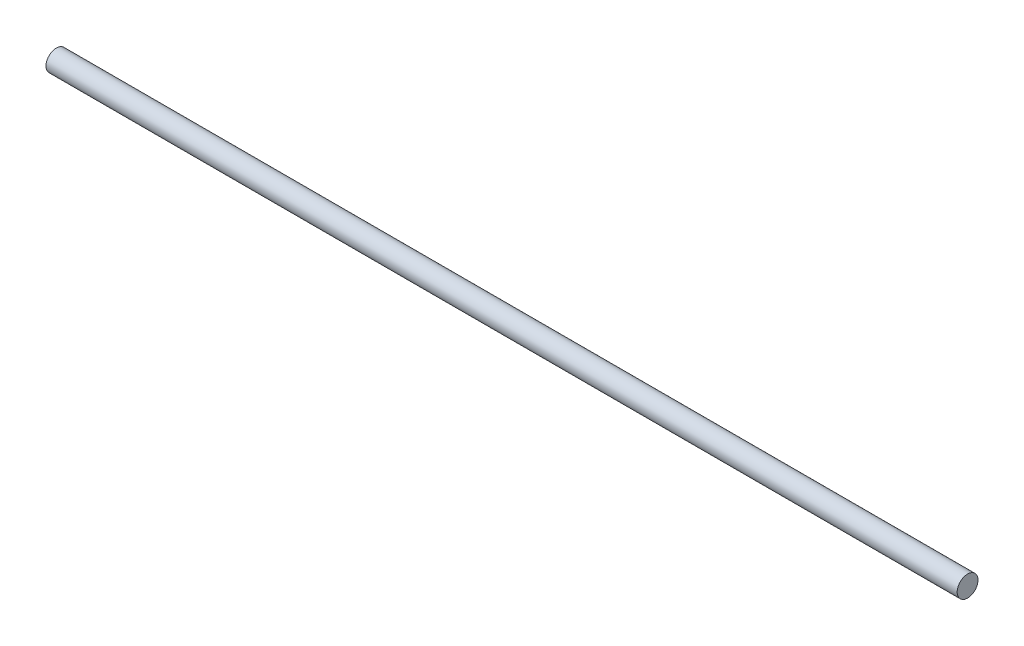
from build123d import *

# Parameters (mm, degrees)
SKETCH1_R           = 4
BOSS_EXTRUDE1_DEPTH = 350


with BuildPart() as part:
    # Sketch1 → Boss-Extrude1 (new body)
    with BuildSketch(Plane(origin=(0, 0, 0), x_dir=(0, 0, -1), z_dir=(1, 0, 0))):
        Circle(SKETCH1_R)
    extrude(amount=BOSS_EXTRUDE1_DEPTH)


solid = part.part
